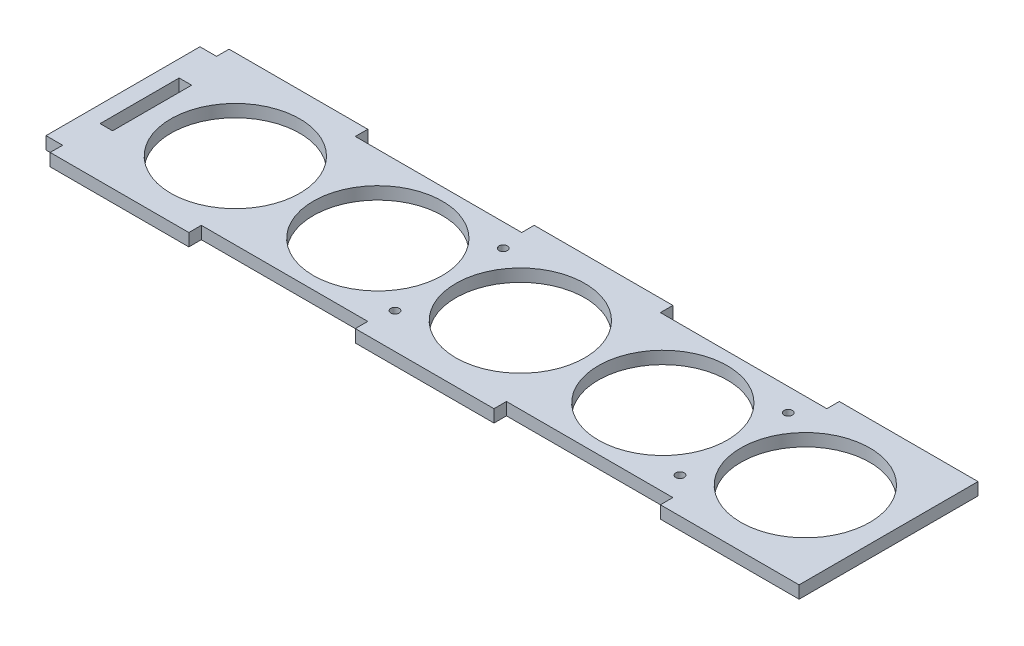
from build123d import *

# Parameters (mm, degrees)
SKETCH1_W           = 3
SKETCH1_H           = 19
SKETCH1_R           = 1
SKETCH1_R_2         = 15.5
BOSS_EXTRUDE1_DEPTH = 3


with BuildPart() as part:
    # Sketch1 → Boss-Extrude1 (new body)
    with BuildSketch(Plane(origin=(0, 0, 0), x_dir=(1, 0, 0), z_dir=(0, 1, 0))):
        Polygon((33.333333333, 21.5), (0, 21.5), (0, 18.5), (-4, 18.5), (-4, -18.5), (0, -18.5), (0, -21.5), (33.333333333, -21.5), (33.333333333, -18.5), (73.333333333, -18.5), (73.333333333, -21.5), (106.666666667, -21.5), (106.666666667, -18.5), (146.666666667, -18.5), (146.666666667, -21.5), (180, -21.5), (180, 21.5), (146.666666667, 21.5), (146.666666667, 18.5), (106.666666667, 18.5), (106.666666667, 21.5), (73.333333333, 21.5), (73.333333333, 18.5), (33.333333333, 18.5), align=None)
        with Locations((1.5, 0)):
            Rectangle(SKETCH1_W, SKETCH1_H, mode=Mode.SUBTRACT)
        with Locations((74.375, -13)):
            Circle(SKETCH1_R, mode=Mode.SUBTRACT)
        with Locations((142.875, -13)):
            Circle(SKETCH1_R, mode=Mode.SUBTRACT)
        with Locations((23, 0)):
            Circle(SKETCH1_R_2, mode=Mode.SUBTRACT)
        with Locations((57.25, 0)):
            Circle(SKETCH1_R_2, mode=Mode.SUBTRACT)
        with Locations((74.375, 13)):
            Circle(SKETCH1_R, mode=Mode.SUBTRACT)
        with Locations((91.5, 0)):
            Circle(SKETCH1_R_2, mode=Mode.SUBTRACT)
        with Locations((125.75, 0)):
            Circle(SKETCH1_R_2, mode=Mode.SUBTRACT)
        with Locations((160, 0)):
            Circle(SKETCH1_R_2, mode=Mode.SUBTRACT)
        with Locations((142.875, 13)):
            Circle(SKETCH1_R, mode=Mode.SUBTRACT)
    extrude(amount=BOSS_EXTRUDE1_DEPTH)


solid = part.part
